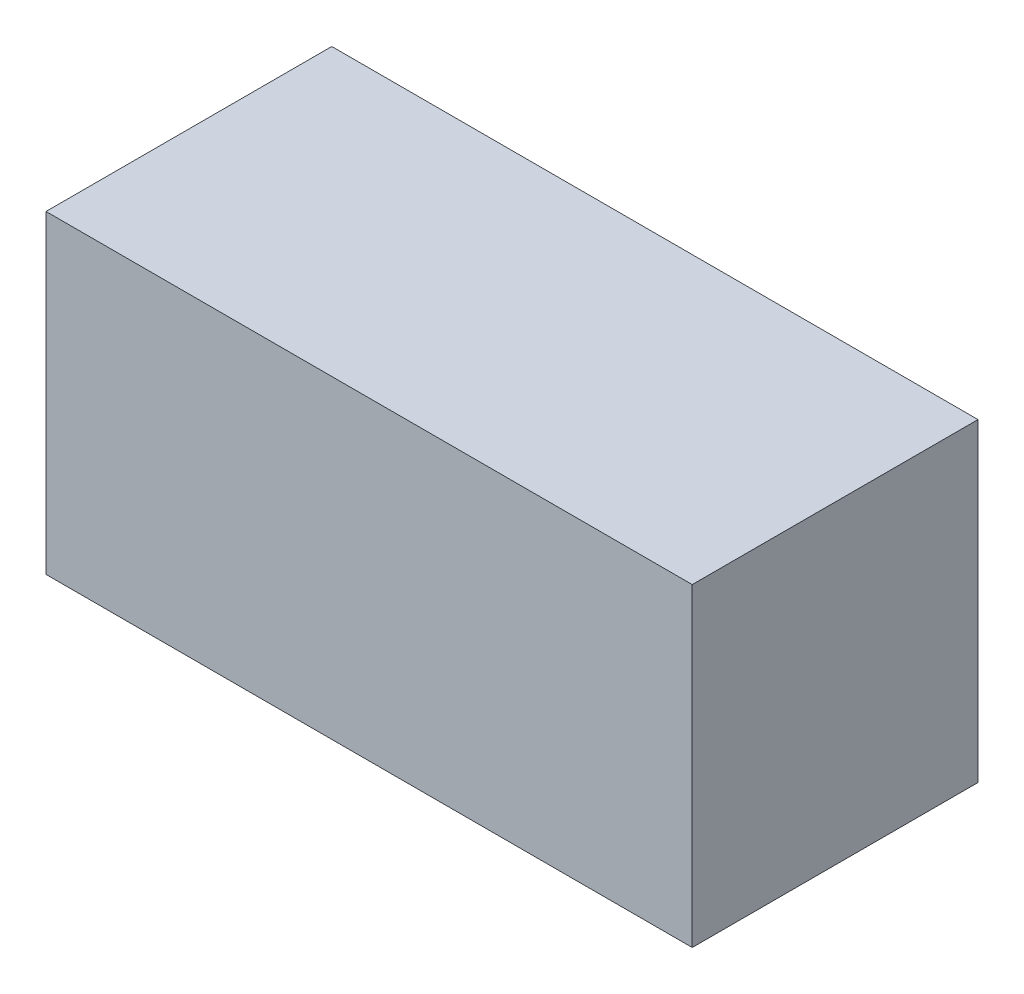
from build123d import *

# Parameters (mm, degrees)
SKETCH1_W      = 560.832
SKETCH1_H      = 248.0056
EXTRUDE1_DEPTH = 136.398


with BuildPart() as part:
    # Sketch1 → Extrude1 (new body, symmetric)
    with BuildSketch(Plane(origin=(0, 0, 0), x_dir=(1, 0, 0), z_dir=(0, 1, 0))):
        Rectangle(SKETCH1_W, SKETCH1_H)
    extrude(amount=EXTRUDE1_DEPTH, both=True)


solid = part.part
